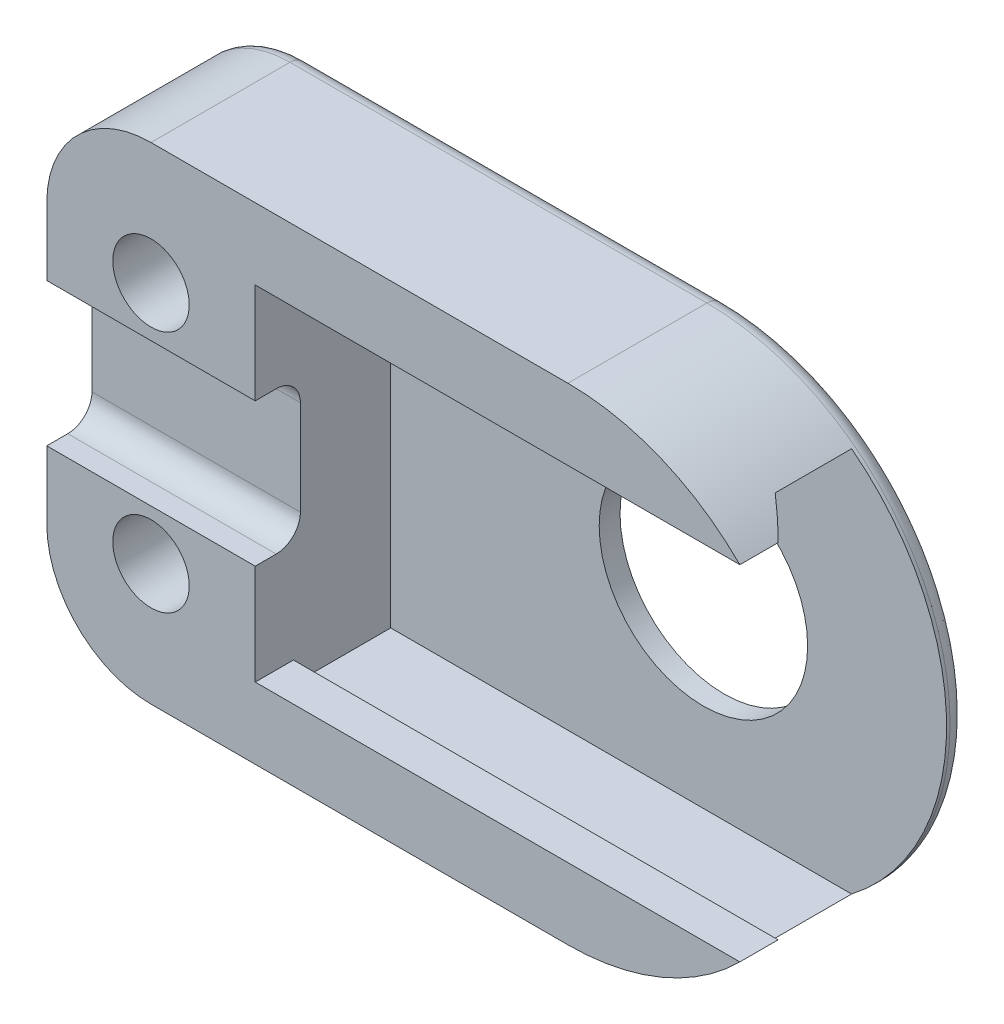
from build123d import *

# Parameters (mm, degrees)
SKETCH1_R           = 1.1
BOSS_EXTRUDE1_DEPTH = 4.5
SKETCH2_R           = 3
CUT_EXTRUDE2_DEPTH  = 10
CUT_EXTRUDE4_START  = -6
CUT_EXTRUDE4_DEPTH  = 17
CUT_EXTRUDE6_DEPTH  = 23
FILLET4_R           = 3
FILLET1_R           = 0.5
SKETCH5_R           = 1.75
CUT_EXTRUDE5_DEPTH  = 1


with BuildPart() as part:
    # Sketch1 → Boss-Extrude1 (new body)
    with BuildSketch(Plane.XY):
        with BuildLine():
            Line((-15, 7), (0, 7))
            ThreePointArc((0, 7), (7, 0), (0, -7))
            Line((0, -7), (-15, -7))
            Line((-15, -7), (-15, 7))
        make_face()
        with Locations((-12, 3.5)):
            Circle(SKETCH1_R, mode=Mode.SUBTRACT)
        with Locations((-12, -3.5)):
            Circle(SKETCH1_R, mode=Mode.SUBTRACT)
    extrude(amount=BOSS_EXTRUDE1_DEPTH)

    # Sketch2 → Cut-Extrude2 (cut)
    with BuildSketch(Plane(origin=(0, 0, 0), x_dir=(-1, 0, 0), z_dir=(0, 0, -1))):
        Circle(SKETCH2_R)
    extrude(amount=-CUT_EXTRUDE2_DEPTH, mode=Mode.SUBTRACT)

    # Sketch7 → Cut-Extrude4 (cut, through all)
    with BuildSketch(Plane.ZY.offset(15).offset(CUT_EXTRUDE4_START)):
        Polygon((2.8, 5.55), (0.6, 5.55), (0.6, 0), (4.5, 0), (4.5, 4.95), (3.4, 4.95), align=None)
        Polygon((4.5, 0), (0.6, 0), (0.6, -5.55), (2.8, -5.55), (3.4, -4.95), (4.5, -4.95), align=None)
    extrude(amount=-CUT_EXTRUDE4_DEPTH, mode=Mode.SUBTRACT)

    # Sketch8 → Cut-Extrude6 (cut, through all)
    with BuildSketch(Plane.ZY.offset(15)):
        with BuildLine():
            Line((3.2, 1.363340016), (3.2, -1.363340016))
            ThreePointArc((3.2, -1.363340016), (3.404046985, -1.855953015), (3.896659984, -2.06))
            Line((3.896659984, -2.06), (4.5, -2.06))
            Line((4.5, -2.06), (4.5, 2.06))
            Line((4.5, 2.06), (3.896659984, 2.06))
            ThreePointArc((3.896659984, 2.06), (3.404046985, 1.855953015), (3.2, 1.363340016))
        make_face()
    extrude(amount=-CUT_EXTRUDE6_DEPTH, mode=Mode.SUBTRACT)

    # Fillet4
    fillet4_edges = [part.edges().sort_by_distance(p)[0] for p in [
        (-15, -7, 2.25),
        (-15, 7, 2.25),
    ]]
    fillet(fillet4_edges, radius=FILLET4_R)

    # Fillet1
    fillet1_edges = [part.edges().sort_by_distance(p)[0] for p in [
        (-6, 7, 0),
        (7, 0, 0),
        (-15, 0, 0),
        (-6, -7, 0),
        (-14.121320344, -6.121320344, 0),
        (-14.121320344, 6.121320344, 0),
    ]]
    fillet(fillet1_edges, radius=FILLET1_R)

    # Sketch5 → Cut-Extrude5 (cut)
    with BuildSketch(Plane.XY):
        with Locations((-12, 3.5)):
            Circle(SKETCH5_R)
        with Locations((-12, -3.5)):
            Circle(SKETCH5_R)
    extrude(amount=CUT_EXTRUDE5_DEPTH, mode=Mode.SUBTRACT)


solid = part.part
